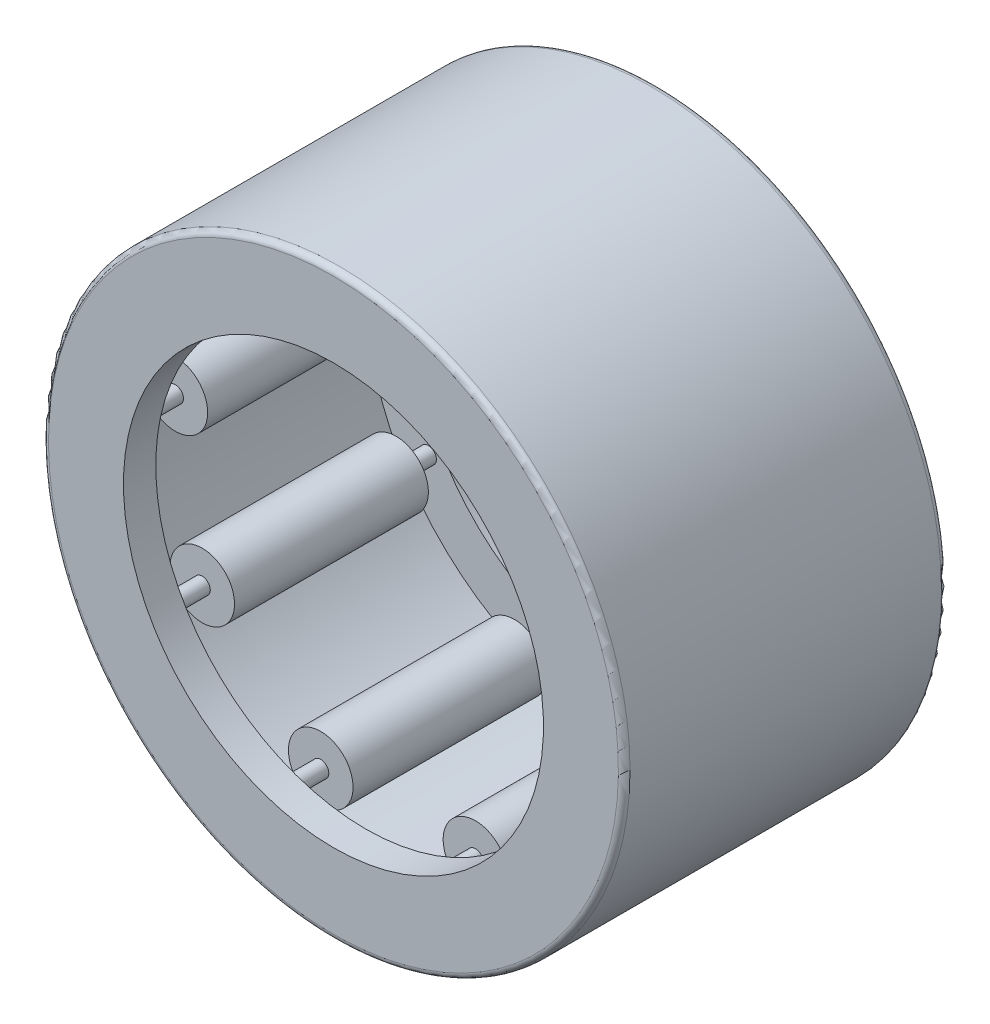
from build123d import *

# Parameters (mm, degrees)
SKETCH2_W         = 4.7625
SKETCH2_H         = 0.5953125
SKETCH3_W         = 6.35
SKETCH3_H         = 0.1984375
CIRPATTERN1_COUNT = 9
CIRPATTERN1_ANGLE = 320
FILLET1_R         = 0.142875


with BuildPart() as part:
    # Sketch1 → Revolve1 (revolve)
    with BuildSketch(Plane(origin=(0, 0, 0), x_dir=(0, 0, -1), z_dir=(1, 0, 0))):
        Polygon((-3.96875, 7.14375), (3.96875, 7.14375), (3.96875, 5.159375), (3.175, 5.159375), (3.175, 6.35), (-3.175, 6.35), (-3.175, 5.159375), (-3.96875, 5.159375), align=None)
    revolve(axis=Axis((0, 0, 3.96875), (0, 0, -1)))

    # Fillet1
    fillet1_edges = [part.edges().sort_by_distance(p)[0] for p in [
        (0, -7.14375, -3.96875),
        (0, -7.14375, 3.96875),
    ]]
    fillet(fillet1_edges, radius=FILLET1_R)


with BuildPart() as body_2:
    # Sketch2 → Revolve2 (revolve)
    with BuildSketch(Plane(origin=(0, 0, 0), x_dir=(0, 0, -1), z_dir=(1, 0, 0))):
        with Locations((0, 6.05234375)):
            Rectangle(SKETCH2_W, SKETCH2_H)
    revolve(axis=Axis((0, 5.55625, 2.38125), (0, 0, -1)))


with BuildPart() as body_3:
    # Sketch3 → Revolve3 (revolve)
    with BuildSketch(Plane(origin=(0, 0, 0), x_dir=(0, 0, -1), z_dir=(1, 0, 0))):
        with Locations((0, 5.65546875)):
            Rectangle(SKETCH3_W, SKETCH3_H)
    revolve(axis=Axis((0, 5.55625, 3.175), (0, 0, -1)))


with BuildPart() as cirpattern1_1:
    # CirPattern1: pattern copy
    add(body_2.part.rotate(Axis((0, 0, -3.96875), (0, 0, 1)), 1 * CIRPATTERN1_ANGLE / (CIRPATTERN1_COUNT - 1)))


with BuildPart() as cirpattern1_2:
    # CirPattern1: pattern copy
    add(body_2.part.rotate(Axis((0, 0, -3.96875), (0, 0, 1)), 2 * CIRPATTERN1_ANGLE / (CIRPATTERN1_COUNT - 1)))


with BuildPart() as cirpattern1_3:
    # CirPattern1: pattern copy
    add(body_2.part.rotate(Axis((0, 0, -3.96875), (0, 0, 1)), 3 * CIRPATTERN1_ANGLE / (CIRPATTERN1_COUNT - 1)))


with BuildPart() as cirpattern1_4:
    # CirPattern1: pattern copy
    add(body_2.part.rotate(Axis((0, 0, -3.96875), (0, 0, 1)), 4 * CIRPATTERN1_ANGLE / (CIRPATTERN1_COUNT - 1)))


with BuildPart() as cirpattern1_5:
    # CirPattern1: pattern copy
    add(body_2.part.rotate(Axis((0, 0, -3.96875), (0, 0, 1)), 5 * CIRPATTERN1_ANGLE / (CIRPATTERN1_COUNT - 1)))


with BuildPart() as cirpattern1_6:
    # CirPattern1: pattern copy
    add(body_2.part.rotate(Axis((0, 0, -3.96875), (0, 0, 1)), 6 * CIRPATTERN1_ANGLE / (CIRPATTERN1_COUNT - 1)))


with BuildPart() as cirpattern1_7:
    # CirPattern1: pattern copy
    add(body_2.part.rotate(Axis((0, 0, -3.96875), (0, 0, 1)), 7 * CIRPATTERN1_ANGLE / (CIRPATTERN1_COUNT - 1)))


with BuildPart() as cirpattern1_8:
    # CirPattern1: pattern copy
    add(body_2.part.rotate(Axis((0, 0, -3.96875), (0, 0, 1)), 8 * CIRPATTERN1_ANGLE / (CIRPATTERN1_COUNT - 1)))


with BuildPart() as cirpattern1_9:
    # CirPattern1: pattern copy
    add(body_3.part.rotate(Axis((0, 0, -3.96875), (0, 0, 1)), 1 * CIRPATTERN1_ANGLE / (CIRPATTERN1_COUNT - 1)))


with BuildPart() as cirpattern1_10:
    # CirPattern1: pattern copy
    add(body_3.part.rotate(Axis((0, 0, -3.96875), (0, 0, 1)), 2 * CIRPATTERN1_ANGLE / (CIRPATTERN1_COUNT - 1)))


with BuildPart() as cirpattern1_11:
    # CirPattern1: pattern copy
    add(body_3.part.rotate(Axis((0, 0, -3.96875), (0, 0, 1)), 3 * CIRPATTERN1_ANGLE / (CIRPATTERN1_COUNT - 1)))


with BuildPart() as cirpattern1_12:
    # CirPattern1: pattern copy
    add(body_3.part.rotate(Axis((0, 0, -3.96875), (0, 0, 1)), 4 * CIRPATTERN1_ANGLE / (CIRPATTERN1_COUNT - 1)))


with BuildPart() as cirpattern1_13:
    # CirPattern1: pattern copy
    add(body_3.part.rotate(Axis((0, 0, -3.96875), (0, 0, 1)), 5 * CIRPATTERN1_ANGLE / (CIRPATTERN1_COUNT - 1)))


with BuildPart() as cirpattern1_14:
    # CirPattern1: pattern copy
    add(body_3.part.rotate(Axis((0, 0, -3.96875), (0, 0, 1)), 6 * CIRPATTERN1_ANGLE / (CIRPATTERN1_COUNT - 1)))


with BuildPart() as cirpattern1_15:
    # CirPattern1: pattern copy
    add(body_3.part.rotate(Axis((0, 0, -3.96875), (0, 0, 1)), 7 * CIRPATTERN1_ANGLE / (CIRPATTERN1_COUNT - 1)))


with BuildPart() as cirpattern1_16:
    # CirPattern1: pattern copy
    add(body_3.part.rotate(Axis((0, 0, -3.96875), (0, 0, 1)), 8 * CIRPATTERN1_ANGLE / (CIRPATTERN1_COUNT - 1)))


solid = Compound([part.part, body_2.part, body_3.part, cirpattern1_1.part, cirpattern1_2.part, cirpattern1_3.part, cirpattern1_4.part, cirpattern1_5.part, cirpattern1_6.part, cirpattern1_7.part, cirpattern1_8.part, cirpattern1_9.part, cirpattern1_10.part, cirpattern1_11.part, cirpattern1_12.part, cirpattern1_13.part, cirpattern1_14.part, cirpattern1_15.part, cirpattern1_16.part])
